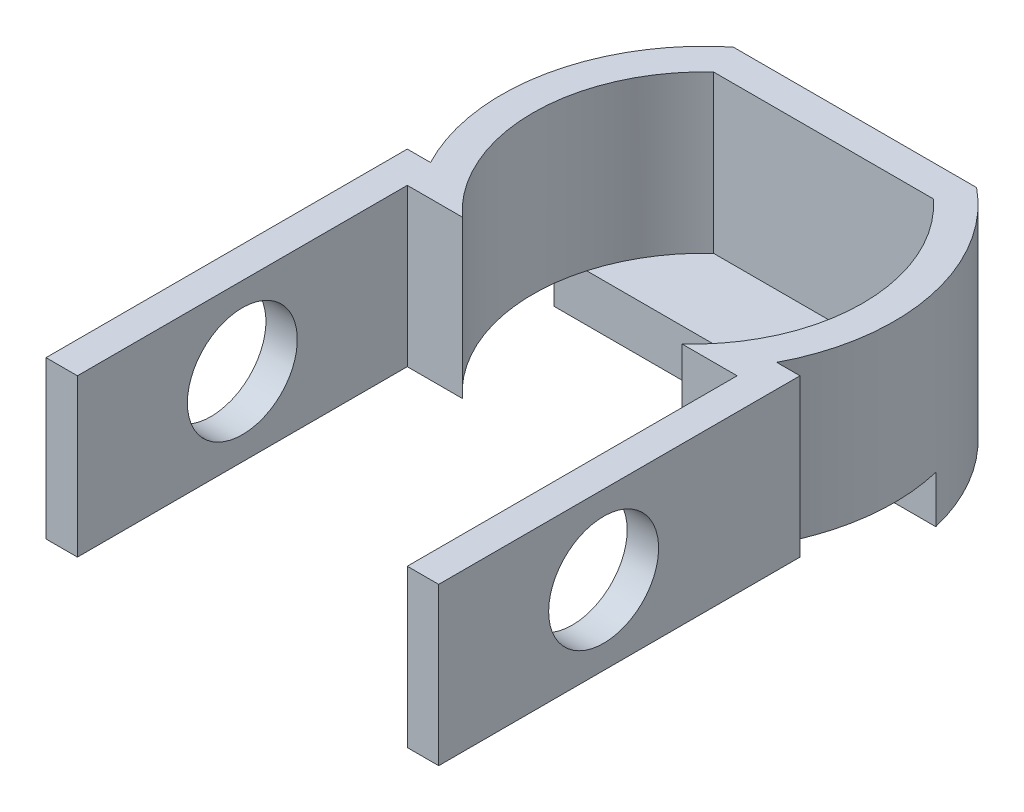
from build123d import *

# Parameters (mm, degrees)
BOSS_EXTRUDE1_DEPTH = 10
SKETCH2_R           = 3.5
CUT_EXTRUDE1_DEPTH  = 26
BOSS_EXTRUDE2_DEPTH = 3


with BuildPart() as part:
    # Sketch1 → Boss-Extrude1 (new body)
    with BuildSketch(Plane(origin=(0, 0, 0), x_dir=(1, 0, 0), z_dir=(0, 1, 0))):
        with BuildLine():
            Line((7, 16), (-7, 16))
            ThreePointArc((-7, 16), (-10.5, 8), (-7, 0))
            Line((-7, 0), (-10.5, 0))
            Line((-10.5, 0), (-10.5, -21))
            Line((-10.5, -21), (-12.5, -21))
            Line((-12.5, -21), (-12.5, 2))
            Line((-12.5, 2), (-11.018793277, 2))
            ThreePointArc((-11.018793277, 2), (-12.238312239, 10.584439081), (-7.745064294, 18))
            Line((-7.745064294, 18), (7.745064294, 18))
            ThreePointArc((7.745064294, 18), (12.238312239, 10.584439081), (11.018793277, 2))
            Line((11.018793277, 2), (12.5, 2))
            Line((12.5, 2), (12.5, -21))
            Line((12.5, -21), (10.5, -21))
            Line((10.5, -21), (10.5, 0))
            Line((10.5, 0), (7, 0))
            ThreePointArc((7, 0), (10.5, 8), (7, 16))
        make_face()
    extrude(amount=BOSS_EXTRUDE1_DEPTH)

    # Sketch2 → Cut-Extrude1 (cut, through all)
    with BuildSketch(Plane.ZY.offset(12.5)):
        with Locations((10.5, 5)):
            Circle(SKETCH2_R)
    extrude(amount=-CUT_EXTRUDE1_DEPTH, mode=Mode.SUBTRACT)

    # Sketch3 → Boss-Extrude2 (add)
    with BuildSketch(Plane.XZ):
        with BuildLine():
            Line((-12.146112723, -11), (12.146112723, -11))
            ThreePointArc((12.146112723, -11), (10.521970317, -14.862383465), (7.745064294, -18))
            Line((7.745064294, -18), (-7.745064294, -18))
            ThreePointArc((-7.745064294, -18), (-10.521970317, -14.862383465), (-12.146112723, -11))
        make_face()
    extrude(amount=BOSS_EXTRUDE2_DEPTH)


solid = part.part
